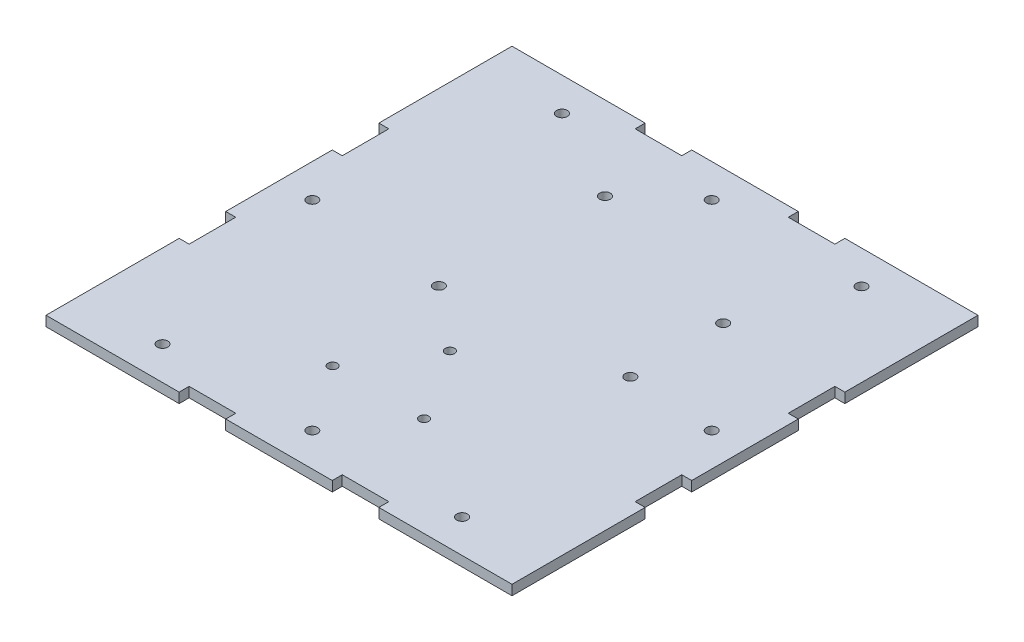
from build123d import *

# Parameters (mm, degrees)
SKETCH2_W           = 140
SKETCH2_H           = 140
SKETCH2_R           = 1.6
SKETCH2_R_2         = 1.4
BOSS_EXTRUDE2_DEPTH = 3
SKETCH3_W           = 14
SKETCH3_H           = 3
SKETCH3_W_2         = 3
SKETCH3_H_2         = 14
CUT_EXTRUDE1_DEPTH  = 10


with BuildPart() as part:
    # Sketch2 → Boss-Extrude2 (new body)
    with BuildSketch(Plane(origin=(0, 0, 0), x_dir=(1, 0, 0), z_dir=(0, 1, 0))):
        Rectangle(SKETCH2_W, SKETCH2_H)
        with Locations((-17.011581703, 44.949159058)):
            Circle(SKETCH2_R, mode=Mode.SUBTRACT)
        with Locations((-18.611581703, -3.350840942)):
            Circle(SKETCH2_R, mode=Mode.SUBTRACT)
        with Locations((33.788418297, 29.649159058)):
            Circle(SKETCH2_R, mode=Mode.SUBTRACT)
        with Locations((33.788418297, 1.749159058)):
            Circle(SKETCH2_R, mode=Mode.SUBTRACT)
        with Locations((0, 60)):
            Circle(SKETCH2_R, mode=Mode.SUBTRACT)
        with Locations((-60, 0)):
            Circle(SKETCH2_R, mode=Mode.SUBTRACT)
        with Locations((0, -60)):
            Circle(SKETCH2_R, mode=Mode.SUBTRACT)
        with Locations((60, 0)):
            Circle(SKETCH2_R, mode=Mode.SUBTRACT)
        with Locations((-45, 60)):
            Circle(SKETCH2_R, mode=Mode.SUBTRACT)
        with Locations((45, 60)):
            Circle(SKETCH2_R, mode=Mode.SUBTRACT)
        with Locations((-45, -60)):
            Circle(SKETCH2_R, mode=Mode.SUBTRACT)
        with Locations((45, -60)):
            Circle(SKETCH2_R, mode=Mode.SUBTRACT)
        with Locations((-0.030225379, -18.62367845)):
            Circle(SKETCH2_R_2, mode=Mode.SUBTRACT)
        with Locations((-13.780225379, -40.12367845)):
            Circle(SKETCH2_R_2, mode=Mode.SUBTRACT)
        with Locations((13.719774621, -40.12367845)):
            Circle(SKETCH2_R_2, mode=Mode.SUBTRACT)
    extrude(amount=BOSS_EXTRUDE2_DEPTH)

    # Sketch3 → Cut-Extrude1 (cut)
    with BuildSketch(Plane(origin=(0, 3, 0), x_dir=(1, 0, 0), z_dir=(0, 1, 0))):
        with Locations((23, -68.5)):
            Rectangle(SKETCH3_W, SKETCH3_H)
        with Locations((23, 68.5)):
            Rectangle(SKETCH3_W, SKETCH3_H)
        with Locations((-23, 68.5)):
            Rectangle(SKETCH3_W, SKETCH3_H)
        with Locations((-23, -68.5)):
            Rectangle(SKETCH3_W, SKETCH3_H)
        with Locations((68.5, -23)):
            Rectangle(SKETCH3_W_2, SKETCH3_H_2)
        with Locations((68.5, 23)):
            Rectangle(SKETCH3_W_2, SKETCH3_H_2)
        with Locations((-68.5, 23)):
            Rectangle(SKETCH3_W_2, SKETCH3_H_2)
        with Locations((-68.5, -23)):
            Rectangle(SKETCH3_W_2, SKETCH3_H_2)
    extrude(amount=-CUT_EXTRUDE1_DEPTH, mode=Mode.SUBTRACT)


solid = part.part
